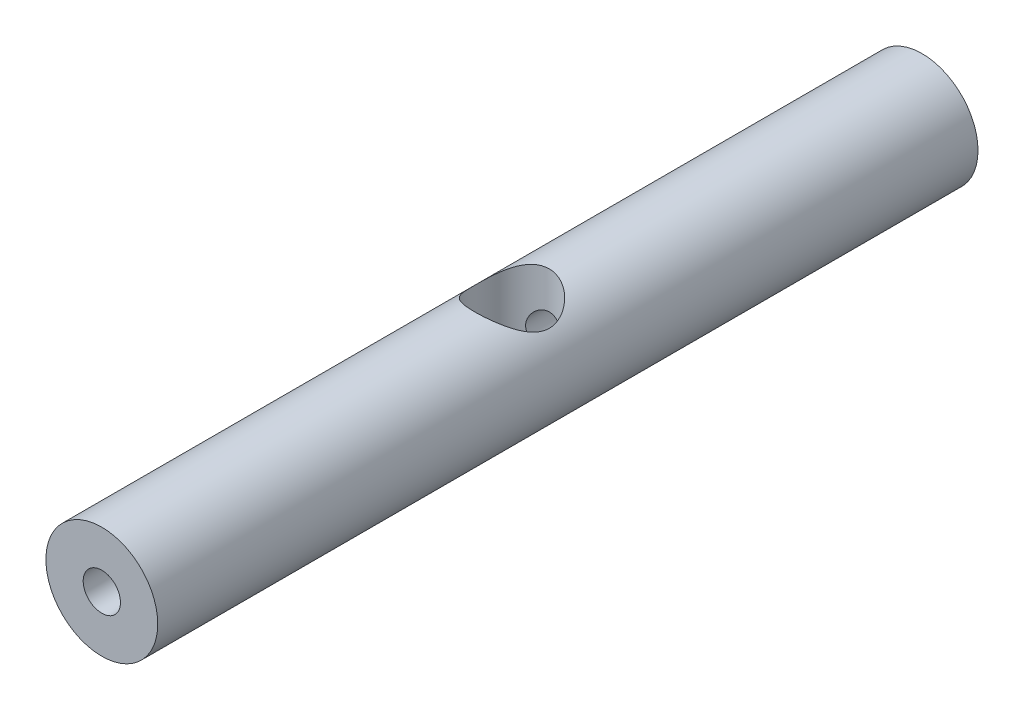
from build123d import *

# Parameters (mm, degrees)
SKETCH1_R               = 9
SKETCH1_R_2             = 3
BOSS_EXTRUDE1_DEPTH     = 132
SKETCH2_R               = 6
CUT_EXTRUDE1_DEPTH      = 10
CUT_EXTRUDE1_DEPTH_BACK = 10


with BuildPart() as part:
    # Sketch1 → Boss-Extrude1 (new body)
    with BuildSketch(Plane.XY):
        Circle(SKETCH1_R)
        Circle(SKETCH1_R_2, mode=Mode.SUBTRACT)
    extrude(amount=BOSS_EXTRUDE1_DEPTH)

    # Sketch2 → Cut-Extrude1 (cut, two sides)
    with BuildSketch(Plane(origin=(0, 0, 0), x_dir=(1, 0, 0), z_dir=(0, 1, 0))) as cut_extrude1_sk:
        with Locations((0, -66)):
            Circle(SKETCH2_R)
    extrude(amount=CUT_EXTRUDE1_DEPTH, mode=Mode.SUBTRACT)
    extrude(cut_extrude1_sk.sketch, amount=-CUT_EXTRUDE1_DEPTH_BACK, mode=Mode.SUBTRACT)


solid = part.part
